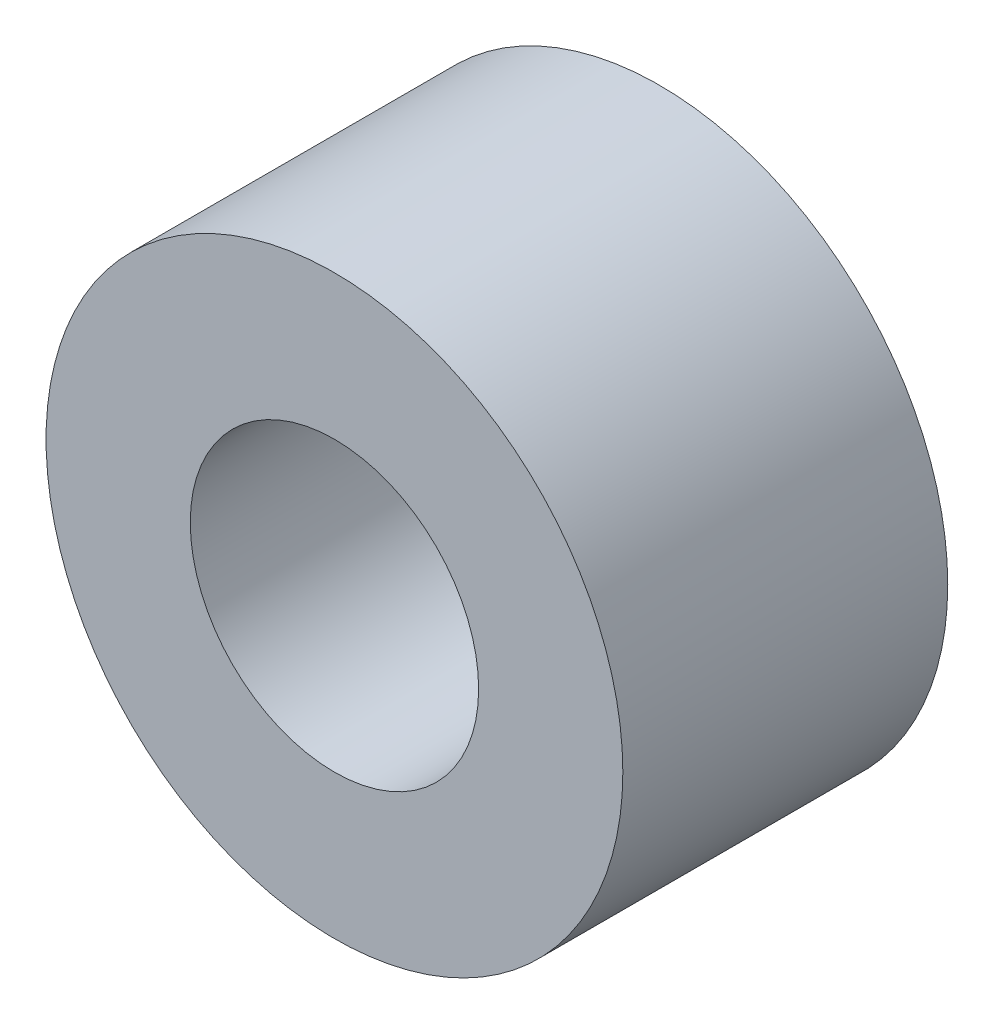
from build123d import *

# Parameters (mm, degrees)
SKETCH1_R           = 3
SKETCH1_R_2         = 1.5
BOSS_EXTRUDE1_DEPTH = 3.38


with BuildPart() as part:
    # Sketch1 → Boss-Extrude1 (new body)
    with BuildSketch(Plane.XY):
        Circle(SKETCH1_R)
        Circle(SKETCH1_R_2, mode=Mode.SUBTRACT)
    extrude(amount=BOSS_EXTRUDE1_DEPTH)


solid = part.part
